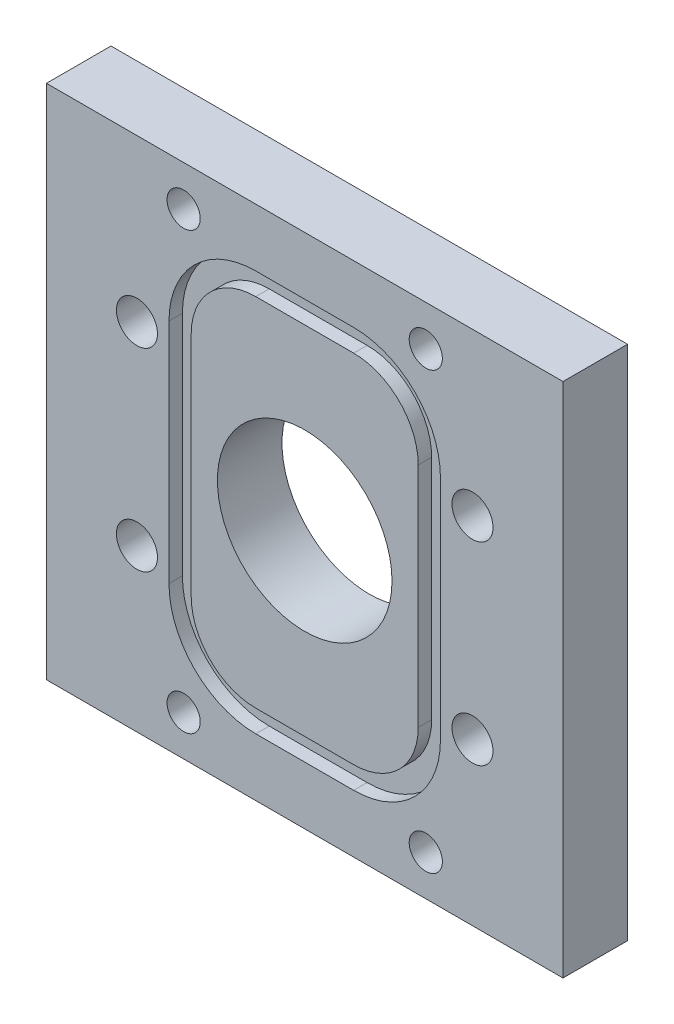
from build123d import *

# Parameters (mm, degrees)
SKETCH1_W                                         = 50.8
SKETCH1_H                                         = 50.8
BOSS_EXTRUDE1_DEPTH                               = 6.35
SKETCH2_R                                         = 8.5852
CUT_EXTRUDE1_DEPTH                                = 7.35
CUT_EXTRUDE2_DASH_027_DEPTH                       = 1.3208
CSK_FOR_4_FLAT_HEAD_MACHINE_SCREW_100_D           = 3.2639
CSK_FOR_4_FLAT_HEAD_MACHINE_SCREW_100_CSINK_D     = 5.715
CSK_FOR_4_FLAT_HEAD_MACHINE_SCREW_100_CSINK_ANGLE = 100
F_10_32_TAPPED_HOLE1_AT_2_COUNT                   = 2
F_10_32_TAPPED_HOLE1_AT_2_PITCH                   = 19.05


with BuildPart() as part:
    # Sketch1 → Boss-Extrude1 (new body)
    with BuildSketch(Plane.XY):
        Rectangle(SKETCH1_W, SKETCH1_H)
    extrude(amount=BOSS_EXTRUDE1_DEPTH)

    # Sketch2 → Cut-Extrude1 (cut, through all)
    with BuildSketch(Plane.XY.offset(6.35)):
        Circle(SKETCH2_R)
    extrude(amount=-CUT_EXTRUDE1_DEPTH, mode=Mode.SUBTRACT)

    # Sketch3 → Cut-Extrude2 - dash 027 (cut)
    with BuildSketch(Plane.XY.offset(6.35)):
        with BuildLine():
            Line((13.3477, -11.176), (13.3477, 11.176))
            ThreePointArc((13.3477, 11.176), (10.848032113, 17.210732113), (4.8133, 19.7104))
            Line((4.8133, 19.7104), (-4.8133, 19.7104))
            ThreePointArc((-4.8133, 19.7104), (-10.848032113, 17.210732113), (-13.3477, 11.176))
            Line((-13.3477, 11.176), (-13.3477, -11.176))
            ThreePointArc((-13.3477, -11.176), (-10.848032113, -17.210732113), (-4.8133, -19.7104))
            Line((-4.8133, -19.7104), (4.8133, -19.7104))
            ThreePointArc((4.8133, -19.7104), (10.848032113, -17.210732113), (13.3477, -11.176))
        make_face()
        with BuildLine():
            Line((-4.8133, -17.526), (4.8133, -17.526))
            ThreePointArc((4.8133, -17.526), (9.303428061, -15.666128061), (11.1633, -11.176))
            Line((11.1633, -11.176), (11.1633, 11.176))
            ThreePointArc((11.1633, 11.176), (9.303428061, 15.666128061), (4.8133, 17.526))
            Line((4.8133, 17.526), (-4.8133, 17.526))
            ThreePointArc((-4.8133, 17.526), (-9.303428061, 15.666128061), (-11.1633, 11.176))
            Line((-11.1633, 11.176), (-11.1633, -11.176))
            ThreePointArc((-11.1633, -11.176), (-9.303428061, -15.666128061), (-4.8133, -17.526))
        make_face(mode=Mode.SUBTRACT)
    extrude(amount=-CUT_EXTRUDE2_DASH_027_DEPTH, mode=Mode.SUBTRACT)

    # CSK for #4 Flat Head Machine Screw (100)1 (through all)
    with Locations(Plane(origin=(0, 0, 0), x_dir=(-1, 0, 0), z_dir=(0, 0, -1))):
        with Locations((-11.90625, 21.43125), (11.90625, 21.43125), (-11.90625, -21.43125), (11.90625, -21.43125)):
            CounterSinkHole(CSK_FOR_4_FLAT_HEAD_MACHINE_SCREW_100_D / 2, CSK_FOR_4_FLAT_HEAD_MACHINE_SCREW_100_CSINK_D / 2, counter_sink_angle=CSK_FOR_4_FLAT_HEAD_MACHINE_SCREW_100_CSINK_ANGLE)

    # Sketch8 → #10-32 Tapped Hole1 (revolve, cut)
    with BuildSketch(Plane(origin=(-16.497783942, 9.525, 0), x_dir=(0, 1, 0), z_dir=(1, 0, 0))):
        Polygon((0, 0), (0, 14.929317848), (2.0193, 13.716), (2.0193, 0), align=None)
    f_10_32_tapped_hole1 = revolve(axis=Axis((-16.497783942, 9.525, -6.35), (0, 0, 1)), mode=Mode.SUBTRACT)

    # #10-32 Tapped Hole1 at 2: #10-32 Tapped Hole1 ×2
    with Locations(*[(0, -i * F_10_32_TAPPED_HOLE1_AT_2_PITCH, 0) for i in range(1, F_10_32_TAPPED_HOLE1_AT_2_COUNT)]):
        add(f_10_32_tapped_hole1, mode=Mode.SUBTRACT)

    # Mirror1: #10-32 Tapped Hole1 across plane
    add(f_10_32_tapped_hole1.mirror(Plane(origin=(0, 0, 0), x_dir=(0, 0, 1), z_dir=(1, 0, 0))), mode=Mode.SUBTRACT)

    # Mirror1 copy 1 sketch → Mirror1 copy 1 (revolve, cut)
    with BuildSketch(Plane(origin=(16.497783942, -9.525, 0), x_dir=(0, 1, 0), z_dir=(-1, 0, 0))):
        Polygon((0, 0), (0, -14.929317848), (2.0193, -13.716), (2.0193, 0), align=None)
    revolve(axis=Axis((16.497783942, -9.525, -6.35), (0, 0, -1)), mode=Mode.SUBTRACT)


solid = part.part
